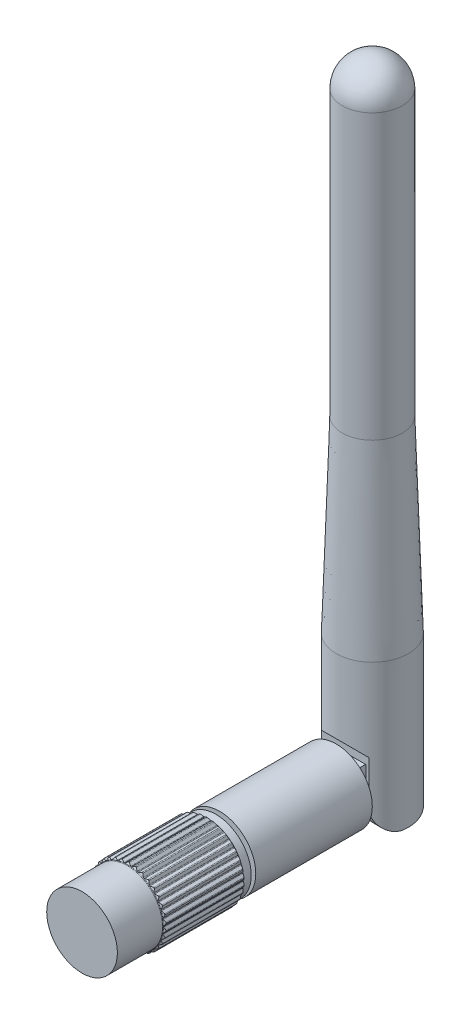
from build123d import *

# Parameters (mm, degrees)
SKETCH2_W                      = 5.5
SKETCH2_H                      = 7.8
CUT_EXTRUDE1_DEPTH             = 8
CUT_EXTRUDE2_REACH             = 6.8
CUT_EXTRUDE2_DIRECTION_2_REACH = 6.8
BOSS_EXTRUDE1_START            = 0.35
BOSS_EXTRUDE1_DEPTH            = 4.8
SKETCH5_R                      = 4.8
BOSS_EXTRUDE2_DEPTH            = 15.5
SKETCH6_R                      = 3.5
BOSS_EXTRUDE3_DEPTH            = 0.5
SKETCH7_R                      = 4.7
BOSS_EXTRUDE4_DEPTH            = 17.8
BOSS_EXTRUDE5_START            = -6
BOSS_EXTRUDE5_DEPTH            = 10.8
CIRPATTERN1_COUNT              = 34


with BuildPart() as part:
    # Sketch1 → Revolve1 (revolve)
    with BuildSketch(Plane(origin=(0, 0, 0), x_dir=(0, 0, -1), z_dir=(1, 0, 0))):
        with BuildLine():
            Line((0, 0), (4.8, 0))
            Line((4.8, 0), (4.8, 20))
            Line((4.8, 20), (4, 45))
            Line((4, 45), (4, 82.7))
            ThreePointArc((4, 82.7), (2.828427125, 85.528427125), (0, 86.7))
            Line((0, 86.7), (0, 0))
        make_face()
    revolve(axis=Axis((0, 0, 0), (0, 1, 0)))

    # Sketch2 → Cut-Extrude1 (cut)
    with BuildSketch(Plane.XZ):
        with Locations((0, 0.9)):
            Rectangle(SKETCH2_W, SKETCH2_H)
    extrude(amount=-CUT_EXTRUDE1_DEPTH, mode=Mode.SUBTRACT)

    # Sketch4 → Cut-Extrude2 (cut, up to next)
    with BuildSketch(Plane(origin=(0, 0, 0), x_dir=(0, 0, -1), z_dir=(1, 0, 0)), mode=Mode.PRIVATE) as cut_extrude2_sk1:
        with BuildLine():
            Line((-4.8, 10.2), (-3.6, 9))
            Line((-3.6, 9), (-3.6, 3))
            ThreePointArc((-3.6, 3), (-2.721320344, 0.878679656), (-0.6, 0))
            Line((-0.6, 0), (-4.8, 0))
            Line((-4.8, 0), (-4.8, 10.2))
        make_face()
    cut_extrude2_tool1 = extrude(cut_extrude2_sk1.sketch, amount=-CUT_EXTRUDE2_REACH, mode=Mode.PRIVATE) & part.part
    add(cut_extrude2_tool1.solids().sort_by_distance((0, 4.212363, 4.028338))[0], mode=Mode.SUBTRACT)

    # Sketch4 → Cut-Extrude2 direction 2 (cut, up to next)
    with BuildSketch(Plane(origin=(0, 0, 0), x_dir=(0, 0, -1), z_dir=(1, 0, 0)), mode=Mode.PRIVATE) as cut_extrude2_direction_2_sk1:
        with BuildLine():
            Line((-4.8, 10.2), (-3.6, 9))
            Line((-3.6, 9), (-3.6, 3))
            ThreePointArc((-3.6, 3), (-2.721320344, 0.878679656), (-0.6, 0))
            Line((-0.6, 0), (-4.8, 0))
            Line((-4.8, 0), (-4.8, 10.2))
        make_face()
    cut_extrude2_direction_2_tool1 = extrude(cut_extrude2_direction_2_sk1.sketch, amount=CUT_EXTRUDE2_DIRECTION_2_REACH, mode=Mode.PRIVATE) & part.part
    add(cut_extrude2_direction_2_tool1.solids().sort_by_distance((0, 4.212363, 4.028338))[0], mode=Mode.SUBTRACT)


with BuildPart() as body_2:
    # Sketch3 → Boss-Extrude1 (new body)
    with BuildSketch(Plane(origin=(-2.75, 0, 0), x_dir=(0, 0, -1), z_dir=(1, 0, 0)).offset(BOSS_EXTRUDE1_START)):
        with BuildLine():
            Line((-4.8, 7.7), (-4.8, 1.9))
            Line((-4.8, 1.9), (0, 1.9))
            ThreePointArc((0, 1.9), (2.9, 4.8), (0, 7.7))
            Line((0, 7.7), (-4.8, 7.7))
        make_face()
    extrude(amount=BOSS_EXTRUDE1_DEPTH)

    # Sketch5 → Boss-Extrude2 (add)
    with BuildSketch(Plane.XY.offset(4.8)):
        with Locations((0, 4.8)):
            Circle(SKETCH5_R)
    extrude(amount=BOSS_EXTRUDE2_DEPTH)

    # Sketch6 → Boss-Extrude3 (add)
    with BuildSketch(Plane.XY.offset(20.3)):
        with Locations((0, 4.8)):
            Circle(SKETCH6_R)
    extrude(amount=BOSS_EXTRUDE3_DEPTH)

    # Sketch7 → Boss-Extrude4 (add)
    with BuildSketch(Plane.XY.offset(20.8)):
        with Locations((0, 4.8)):
            Circle(SKETCH7_R)
    extrude(amount=BOSS_EXTRUDE4_DEPTH)

    # Sketch8 → Boss-Extrude5 (add)
    with BuildSketch(Plane.XY.offset(38.6).offset(BOSS_EXTRUDE5_START)):
        with BuildLine():
            Line((-0.433661289, 0.120049371), (-0.438274707, 0.070262663))
            ThreePointArc((-0.438274707, 0.070262663), (-0.400135005, 0.064040354), (-0.365950586, 0.046018715))
            Line((-0.365950586, 0.046018715), (-0.072324121, -0.175756052))
            ThreePointArc((-0.072324121, -0.175756052), (0, -0.2), (0.072324121, -0.175756052))
            Line((0.072324121, -0.175756052), (0.365950586, 0.046018715))
            ThreePointArc((0.365950586, 0.046018715), (0.400135005, 0.064040354), (0.438274707, 0.070262663))
            Line((0.438274707, 0.070262663), (0.433661289, 0.120049371))
            Line((0.433661289, 0.120049371), (-0.433661289, 0.120049371))
        make_face()
    boss_extrude5 = extrude(amount=-BOSS_EXTRUDE5_DEPTH)

    # CirPattern1: Boss-Extrude5 ×34 about axis
    cirpattern1_axis = Axis((0, 4.8, 0), (0, 0, 1))
    for i in range(1, CIRPATTERN1_COUNT):
        add(boss_extrude5.rotate(cirpattern1_axis, i * 360 / CIRPATTERN1_COUNT))

    # Sketch9 → Cut-Revolve1 (revolve, cut)
    with BuildSketch(Plane(origin=(0, 0, 0), x_dir=(0, 0, -1), z_dir=(1, 0, 0))):
        with BuildLine():
            Line((-32.51339746, 9.55), (-32.397927406, 9.75))
            ThreePointArc((-32.397927406, 9.75), (-32.361324865, 9.78660254), (-32.311324865, 9.8))
            Line((-32.311324865, 9.8), (-32.6, 9.8))
            Line((-32.6, 9.8), (-32.6, 9.5))
            ThreePointArc((-32.6, 9.5), (-32.55, 9.51339746), (-32.51339746, 9.55))
        make_face()
        with BuildLine():
            Line((-21.88660254, 9.55), (-22.002072594, 9.75))
            ThreePointArc((-22.002072594, 9.75), (-22.038675135, 9.78660254), (-22.088675135, 9.8))
            Line((-22.088675135, 9.8), (-21.8, 9.8))
            Line((-21.8, 9.8), (-21.8, 9.5))
            ThreePointArc((-21.8, 9.5), (-21.85, 9.51339746), (-21.88660254, 9.55))
        make_face()
    revolve(axis=Axis((0, 4.8, 20.8), (0, 0, 1)), mode=Mode.SUBTRACT)


solid = Compound([part.part, body_2.part])
